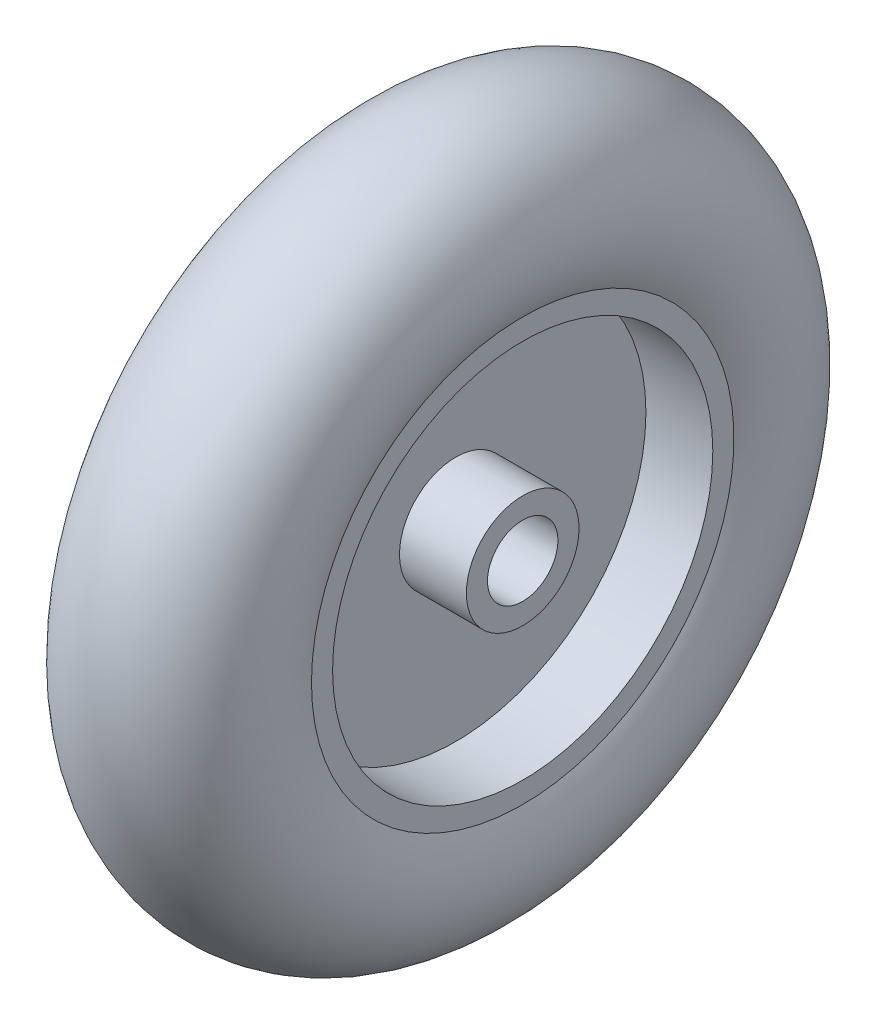
from build123d import *


with BuildPart() as part:
    # Sketch1 → Revolve1 (revolve)
    with BuildSketch(Plane(origin=(0, 0, 0), x_dir=(1, 0, 0), z_dir=(0, 1, 0))):
        with BuildLine():
            Line((-12, 8), (-2.5, 8))
            Line((-2.5, 8), (-2.5, 27))
            Line((-2.5, 27), (-12, 27))
            Line((-12, 27), (-12, 30))
            ThreePointArc((-12, 30), (0, 50), (12, 30))
            Line((12, 30), (12, 27))
            Line((12, 27), (2.5, 27))
            Line((2.5, 27), (2.5, 8))
            Line((2.5, 8), (12, 8))
            Line((12, 8), (12, 5))
            Line((12, 5), (-12, 5))
            Line((-12, 5), (-12, 8))
        make_face()
    revolve(axis=Axis((-7.022018073, 0, 0), (1, 0, 0)))


solid = part.part
